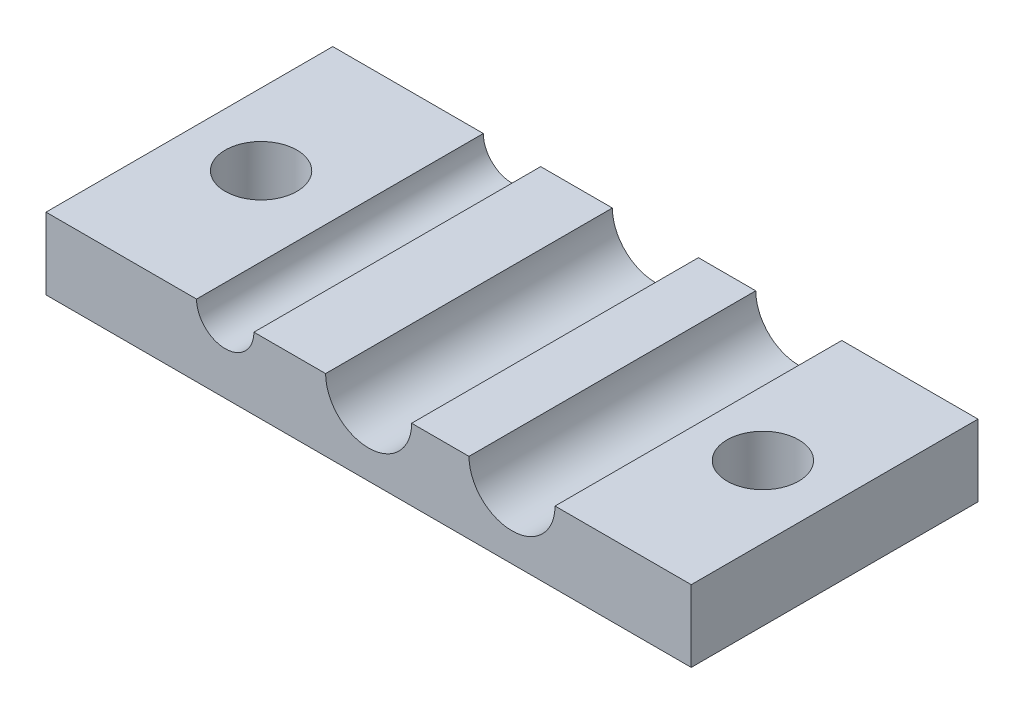
from build123d import *

# Parameters (mm, degrees)
BOSS_EXTRUDE1_DEPTH = 20
SKETCH2_R           = 2.5
CUT_EXTRUDE1_DEPTH  = 20
SKETCH3_W           = 45
SKETCH3_H           = 40
CUT_EXTRUDE2_DEPTH  = 20


with BuildPart() as part:
    # Sketch1 → Boss-Extrude1 (new body)
    with BuildSketch(Plane.XY):
        with BuildLine():
            Line((-22.5, -22.5), (22.5, -22.5))
            Line((22.5, -22.5), (22.5, 22.5))
            Line((22.5, 22.5), (13, 22.5))
            ThreePointArc((13, 22.5), (10, 19.5), (7, 22.5))
            Line((7, 22.5), (3, 22.5))
            ThreePointArc((3, 22.5), (0, 19.5), (-3, 22.5))
            Line((-3, 22.5), (-8, 22.5))
            ThreePointArc((-8, 22.5), (-10, 20.5), (-12, 22.5))
            Line((-12, 22.5), (-22.5, 22.5))
            Line((-22.5, 22.5), (-22.5, -22.5))
        make_face()
    extrude(amount=BOSS_EXTRUDE1_DEPTH)

    # Sketch2 → Cut-Extrude1 (cut)
    with BuildSketch(Plane(origin=(0, 22.5, 0), x_dir=(1, 0, 0), z_dir=(0, 1, 0))):
        with Locations((-17.5, -10)):
            Circle(SKETCH2_R)
        with Locations((17.5, -10)):
            Circle(SKETCH2_R)
    extrude(amount=-CUT_EXTRUDE1_DEPTH, mode=Mode.SUBTRACT)

    # Sketch3 → Cut-Extrude2 (cut)
    with BuildSketch(Plane(origin=(0, 0, 0), x_dir=(-1, 0, 0), z_dir=(0, 0, -1))):
        with Locations((0, -2.5)):
            Rectangle(SKETCH3_W, SKETCH3_H)
    extrude(amount=-CUT_EXTRUDE2_DEPTH, mode=Mode.SUBTRACT)


solid = part.part
